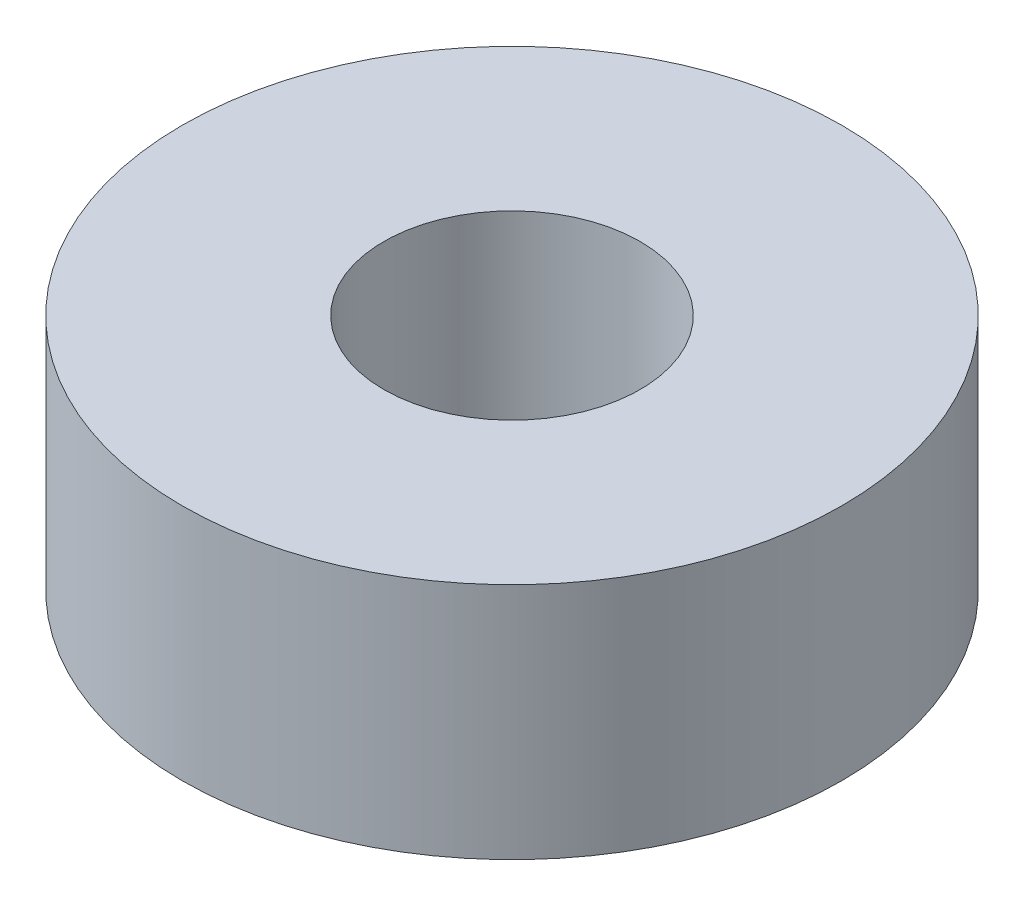
from build123d import *

# Parameters (mm, degrees)
SKETCH_1_R      = 9
SKETCH_1_R_2    = 3.5
EXTRUDE_1_DEPTH = 3.25


with BuildPart() as part:
    # 草图1 → 凸台-拉伸1 (new body, symmetric)
    with BuildSketch(Plane(origin=(0, 0, 0), x_dir=(1, 0, 0), z_dir=(0, 1, 0))):
        Circle(SKETCH_1_R)
        Circle(SKETCH_1_R_2, mode=Mode.SUBTRACT)
    extrude(amount=EXTRUDE_1_DEPTH, both=True)


solid = part.part
